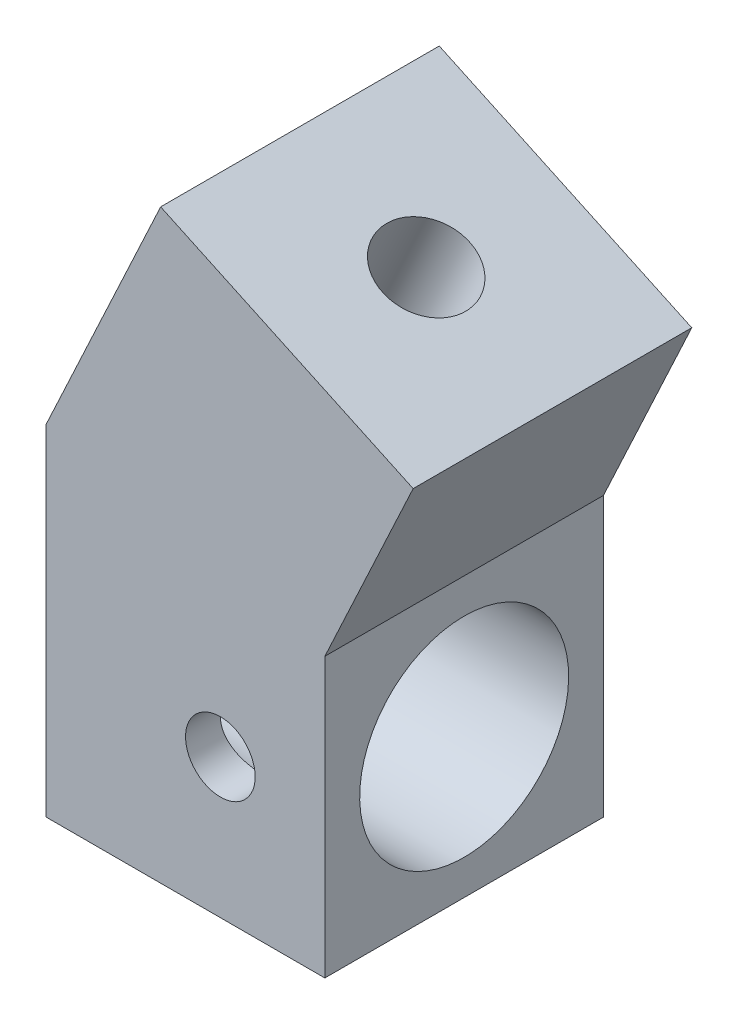
from build123d import *

# Parameters (mm, degrees)
BOSS_EXTRUDE1_DEPTH = 8
CUT_EXTRUDE1_REACH  = 10
SKETCH3_R           = 3
CUT_EXTRUDE2_REACH  = 10
SKETCH4_R           = 1
SKETCH5_R           = 1.25
CUT_EXTRUDE3_DEPTH  = 3


with BuildPart() as part:
    # Sketch2 → Boss-Extrude1 (new body)
    with BuildSketch(Plane.XY):
        Polygon((8, 0), (0, 0), (0, 9.773557301), (3.285247274, 16.818792816), (10.53570957, 13.437846722), (8, 8), align=None)
    extrude(amount=BOSS_EXTRUDE1_DEPTH)

    # Sketch3 → Cut-Extrude1 (cut, up to next)
    with BuildSketch(Plane(origin=(8, 0, 0), x_dir=(0, 0, -1), z_dir=(1, 0, 0)), mode=Mode.PRIVATE) as cut_extrude1_sk1:
        with Locations((-4, 4)):
            Circle(SKETCH3_R)
    cut_extrude1_tool1 = extrude(cut_extrude1_sk1.sketch, amount=-CUT_EXTRUDE1_REACH, mode=Mode.PRIVATE) & part.part
    add(cut_extrude1_tool1.solids().sort_by_distance((8, 4, 4))[0], mode=Mode.SUBTRACT)

    # Sketch4 → Cut-Extrude2 (cut, up to next)
    with BuildSketch(Plane.XY.offset(8), mode=Mode.PRIVATE) as cut_extrude2_sk1:
        with Locations((5, 4)):
            Circle(SKETCH4_R)
    cut_extrude2_tool1 = extrude(cut_extrude2_sk1.sketch, amount=-CUT_EXTRUDE2_REACH, mode=Mode.PRIVATE) & part.part
    add(cut_extrude2_tool1.solids().sort_by_distance((5, 4, 8))[0], mode=Mode.SUBTRACT)

    # Sketch5 → Cut-Extrude3 (cut)
    with BuildSketch(Plane(origin=(7.028736904, 15.073174933, 0), x_dir=(0.906307787, -0.422618262, 0), z_dir=(0.422618262, 0.906307787, 0))):
        with Locations((-0.130483798, -4)):
            Circle(SKETCH5_R)
    extrude(amount=-CUT_EXTRUDE3_DEPTH, mode=Mode.SUBTRACT)


solid = part.part
